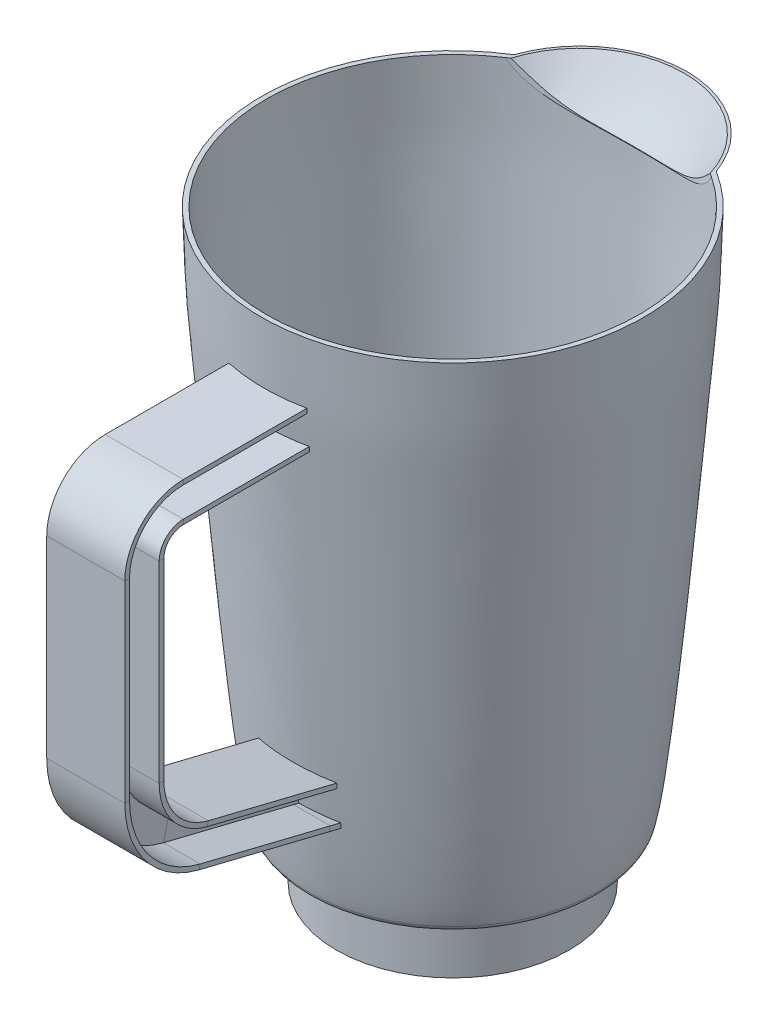
from build123d import *

# Parameters (mm, degrees)
SKETCH16_R = 60.701936
SKETCH15_R = 46.741097153


with BuildPart() as part:
    # Sketch1 → Revolve1 (revolve)
    with BuildSketch(Plane(origin=(0, 0, 0), x_dir=(0, 0, -1), z_dir=(1, 0, 0))):
        with BuildLine():
            Line((37.8587, 0), (31.5087, 0))
            Line((31.5087, 0), (31.5087, 1.524))
            Line((31.5087, 1.524), (36.3347, 1.524))
            Line((36.3347, 1.524), (36.3347, 20.574))
            Line((36.3347, 20.574), (44.344324647, 20.574))
            ThreePointArc((44.344324647, 20.574), (45.968645506, 21.161263011), (46.8418612, 22.651494687))
            add(Edge.make_bspline(
                [(60.701936, 190.5), (59.604787642, 162.659825468), (60.534596922, 179.193598598), (49.430717485, 36.631362644), (46.8418612, 22.651494687)],
                knots=[0, 0, 0, 0, 0.492124829, 0.952522396, 0.952522396, 0.952522396, 0.952522396], degree=3))
            Line((60.701936, 190.5), (62.225936, 190.5))
            add(Edge.make_bspline(
                [(62.225936, 190.5), (61.227916459, 162.659895285), (62.277303723, 180.186369767), (50.435129657, 34.492633046), (47.00118544, 20.965048393)],
                knots=[0, 0, 0, 0, 0.493366755, 0.955966186, 0.955966186, 0.955966186, 0.955966186], degree=3))
            ThreePointArc((47.00118544, 20.965048393), (46.098791235, 19.585133785), (44.539268405, 19.05))
            Line((44.539268405, 19.05), (37.8587, 19.05))
            Line((37.8587, 19.05), (37.8587, 0))
        make_face()
    revolve(axis=Axis((0, 190.5, 0), (0, -1, 0)))

    # Sweep4: sweep along a path in Sketch4
    with BuildLine(Plane(origin=(0, 0, 0), x_dir=(0, 0, -1), z_dir=(1, 0, 0))) as sweep4_path:
        Line((-22.07842485, 46.190831025), (-51.366819953, 53.40095496))
        Line((-51.366819953, 53.40095496), (-93.697554016, 63.82180041))
        ThreePointArc((-93.697554016, 63.82180041), (-107.618173214, 72.817950181), (-113.025936, 88.485446829))
        Line((-113.025936, 88.485446829), (-113.025936, 151.13))
        ThreePointArc((-113.025936, 151.13), (-109.306192121, 160.110256121), (-100.325936, 163.83))
        Line((-100.325936, 163.83), (-62.225936, 163.83))
        Line((-62.225936, 163.83), (-52.965683694, 163.83))
    # Sketch3 → Sweep4 (sweep)
    with BuildSketch(Plane(origin=(0, 190.5, 62.225936), x_dir=(-1, 0, 0), z_dir=(0, 0, -1))):
        Polygon((12.7, -20.32), (-12.7, -20.32), (-12.7, -21.844), (-0.762, -21.844), (-0.762, -31.496), (-12.7, -31.496), (-12.7, -33.02), (12.7, -33.02), (12.7, -31.496), (0.762, -31.496), (0.762, -21.844), (12.7, -21.844), align=None)
    sweep(path=sweep4_path.line)

    # Sketch11 → Revolve2 (revolve)
    with BuildSketch(Plane(origin=(0, 0, 0), x_dir=(0, 0, -1), z_dir=(1, 0, 0))):
        with BuildLine():
            add(Edge.make_bspline(
                [(76.195936, 190.5), (71.971042676, 182.371498295), (60.425186626, 176.696585947), (50.598784317, 174.640264762), (41.397936, 174.011539351)],
                knots=[0, 0, 0, 0, 0.507168284, 1, 1, 1, 1], degree=3))
            Line((41.397936, 174.011539351), (41.397936, 175.535539351))
            add(Edge.make_bspline(
                [(74.671936, 190.5), (69.792971678, 182.118886365), (60.612266224, 178.862130346), (50.429357452, 176.006375858), (41.397936, 175.535539351)],
                knots=[0, 0, 0, 0, 0.482413895, 1, 1, 1, 1], degree=3))
            Line((74.671936, 190.5), (76.195936, 190.5))
        make_face()
    revolve(axis=Axis((0, 190.5, -41.397936), (0, -1, 0)))

    # Sketch13 → Cut-Revolve1 (revolve, cut)
    with BuildSketch(Plane(origin=(0, 190.5, -41.402), x_dir=(-1, 0, 0), z_dir=(0, 0, -1))):
        with BuildLine():
            Line((0, 0), (0, -15.24))
            add(Edge.make_bspline(
                [(0, -15.24), (21.866624565, -14.903448537), (25.20315281, -11.194814851), (33.916198044, 0)],
                knots=[0, 0, 0, 0, 1, 1, 1, 1], degree=3))
            Line((33.916198044, 0), (0, 0))
        make_face()
    revolve(axis=Axis((0, 190.5, -41.402), (0, -1, 0)), mode=Mode.SUBTRACT)

    # Sketch16 → Cut-Loft1 section 0
    with BuildSketch(Plane(origin=(0, 190.5, 0), x_dir=(1, 0, 0), z_dir=(0, 1, 0))):
        Circle(SKETCH16_R)
    # Sketch15 → Cut-Loft1 section 1
    with BuildSketch(Plane(origin=(0, 23.114, 0), x_dir=(1, 0, 0), z_dir=(0, 1, 0))):
        Circle(SKETCH15_R)
    loft(mode=Mode.SUBTRACT)


solid = part.part
